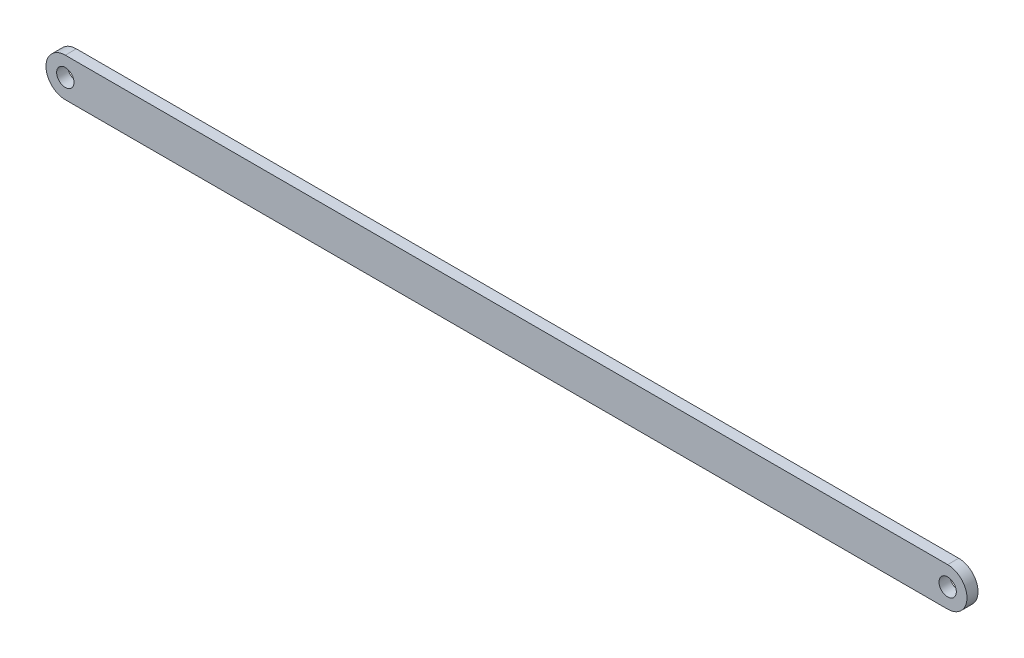
from build123d import *

# Parameters (mm, degrees)
BOSS_EXTRUDE1_DEPTH = 2.54


with BuildPart() as part:
    # Sketch1 → Boss-Extrude1 (new body)
    with BuildSketch(Plane.XY):
        with BuildLine():
            Line((101.6, 4.445), (-101.6, 4.445))
            ThreePointArc((-101.6, 4.445), (-98.456910358, 3.143089642), (-97.155, 0))
            ThreePointArc((-97.155, 0), (-98.456910358, -3.143089642), (-101.6, -4.445))
            Line((-101.6, -4.445), (101.6, -4.445))
            ThreePointArc((101.6, -4.445), (97.155, 0), (101.6, 4.445))
        make_face()
        with BuildLine():
            ThreePointArc((-97.155, 0), (-98.456910358, 3.143089642), (-101.6, 4.445))
            Line((-101.6, 4.445), (-101.6, 1.9939))
            ThreePointArc((-101.6, 1.9939), (-100.190099789, 1.409900211), (-99.6061, 0))
            ThreePointArc((-99.6061, 0), (-100.190099789, -1.409900211), (-101.6, -1.9939))
            Line((-101.6, -1.9939), (-101.6, -4.445))
            ThreePointArc((-101.6, -4.445), (-98.456910358, -3.143089642), (-97.155, 0))
        make_face()
        with BuildLine():
            Line((-101.6, 1.9939), (-101.6, 4.445))
            ThreePointArc((-101.6, 4.445), (-106.045, 0), (-101.6, -4.445))
            Line((-101.6, -4.445), (-101.6, -1.9939))
            ThreePointArc((-101.6, -1.9939), (-103.5939, 0), (-101.6, 1.9939))
        make_face()
        with BuildLine():
            ThreePointArc((106.045, 0), (104.743089642, 3.143089642), (101.6, 4.445))
            Line((101.6, 4.445), (101.6, 1.9939))
            ThreePointArc((101.6, 1.9939), (103.009900211, 1.409900211), (103.5939, 0))
            ThreePointArc((103.5939, 0), (103.009900211, -1.409900211), (101.6, -1.9939))
            Line((101.6, -1.9939), (101.6, -4.445))
            ThreePointArc((101.6, -4.445), (104.743089642, -3.143089642), (106.045, 0))
        make_face()
        with BuildLine():
            Line((101.6, 1.9939), (101.6, 4.445))
            ThreePointArc((101.6, 4.445), (97.155, 0), (101.6, -4.445))
            Line((101.6, -4.445), (101.6, -1.9939))
            ThreePointArc((101.6, -1.9939), (99.6061, 0), (101.6, 1.9939))
        make_face()
    extrude(amount=BOSS_EXTRUDE1_DEPTH)


solid = part.part
